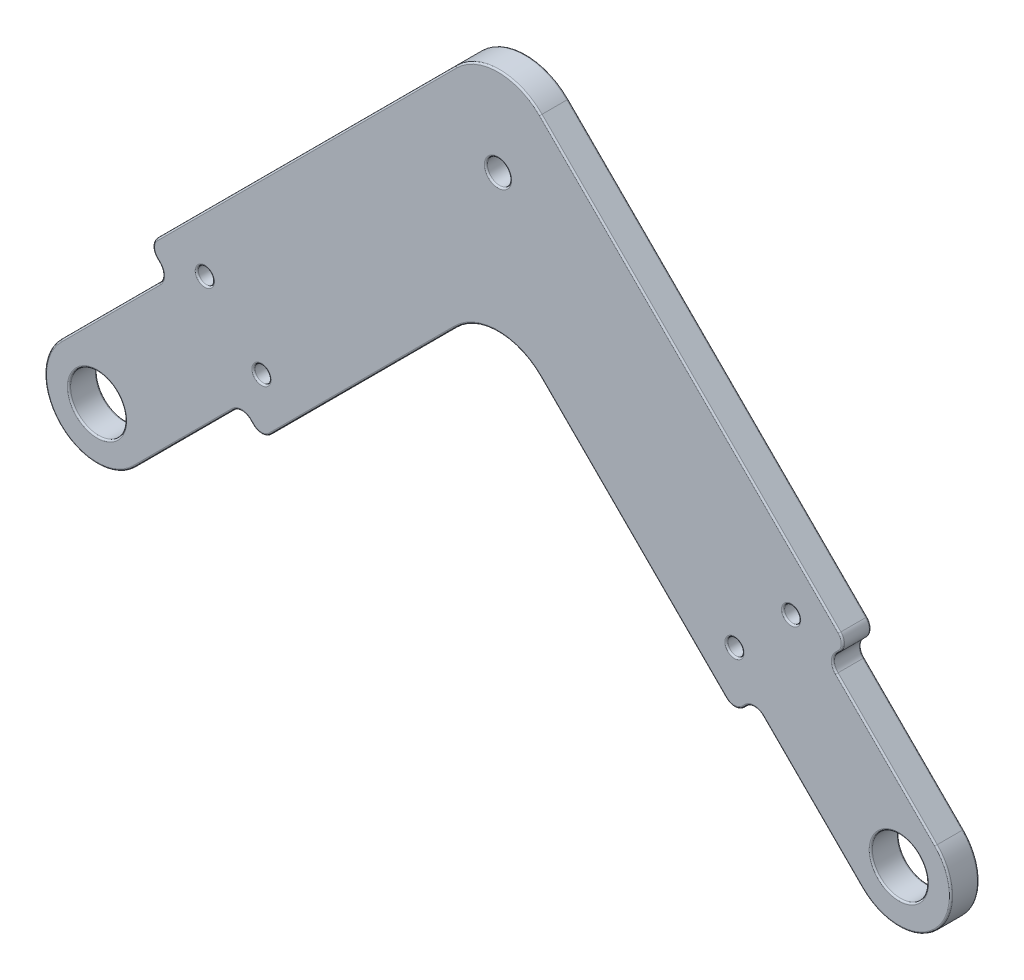
from build123d import *

# Parameters (mm, degrees)
SKETCH3_R           = 3.5
SKETCH3_R_2         = 1
SKETCH3_R_3         = 1.5
BOSS_EXTRUDE1_DEPTH = 3.5
FILLET1_R           = 7.5
FILLET2_R           = 1.5
FILLET3_R           = 0.2


with BuildPart() as part:
    # Sketch3 → Boss-Extrude1 (new body)
    with BuildSketch(Plane.XY):
        with BuildLine():
            Line((-79.493903346, 6.363961031), (-50, 35.857864376))
            Line((-50, 35.857864376), (-20.506096654, 6.363961031))
            Line((-20.506096654, 6.363961031), (-18.03122292, 8.838834765))
            Line((-18.03122292, 8.838834765), (-4.596194078, -4.596194078))
            ThreePointArc((-4.596194078, -4.596194078), (4.596194078, -4.596194078), (4.596194078, 4.596194078))
            Line((4.596194078, 4.596194078), (-8.838834765, 18.03122292))
            Line((-8.838834765, 18.03122292), (-6.363961031, 20.506096654))
            Line((-6.363961031, 20.506096654), (-50, 64.142135624))
            Line((-50, 64.142135624), (-93.636038969, 20.506096654))
            Line((-93.636038969, 20.506096654), (-91.161165235, 18.03122292))
            Line((-91.161165235, 18.03122292), (-104.596194078, 4.596194078))
            ThreePointArc((-104.596194078, 4.596194078), (-104.596194078, -4.596194078), (-95.403805922, -4.596194078))
            Line((-95.403805922, -4.596194078), (-81.96877708, 8.838834765))
            Line((-81.96877708, 8.838834765), (-79.493903346, 6.363961031))
        make_face()
        with Locations((-100, 0)):
            Circle(SKETCH3_R, mode=Mode.SUBTRACT)
        Circle(SKETCH3_R, mode=Mode.SUBTRACT)
        with Locations((-86.564971157, 20.506096654)):
            Circle(SKETCH3_R_2, mode=Mode.SUBTRACT)
        with Locations((-79.493903346, 13.435028843)):
            Circle(SKETCH3_R_2, mode=Mode.SUBTRACT)
        with Locations((-13.435028843, 20.506096654)):
            Circle(SKETCH3_R_2, mode=Mode.SUBTRACT)
        with Locations((-20.506096654, 13.435028843)):
            Circle(SKETCH3_R_2, mode=Mode.SUBTRACT)
        with Locations((-50, 50)):
            Circle(SKETCH3_R_3, mode=Mode.SUBTRACT)
    extrude(amount=BOSS_EXTRUDE1_DEPTH)

    # Fillet1
    fillet1_edges = [part.edges().sort_by_distance(p)[0] for p in [
        (-50, 64.142135624, 1.75),
        (-50, 35.857864376, 1.75),
    ]]
    fillet(fillet1_edges, radius=FILLET1_R)

    # Fillet2
    fillet2_edges = [part.edges().sort_by_distance(p)[0] for p in [
        (-81.96877708, 8.838834765, 1.75),
        (-91.161165235, 18.03122292, 1.75),
        (-93.636038969, 20.506096654, 1.75),
        (-6.363961031, 20.506096654, 1.75),
        (-8.838834765, 18.03122292, 1.75),
        (-18.03122292, 8.838834765, 1.75),
        (-20.506096654, 6.363961031, 1.75),
        (-79.493903346, 6.363961031, 1.75),
    ]]
    fillet(fillet2_edges, radius=FILLET2_R)

    # Fillet3
    fillet3_edges = [part.edges().sort_by_distance(p)[0] for p in [
        (-91.782485579, 18.03122292, 0),
        (-91.782485579, 18.03122292, 3.5),
        (-81.96877708, 8.217514421, 0),
        (-81.96877708, 8.217514421, 3.5),
        (-18.03122292, 8.217514421, 0),
        (-18.03122292, 8.217514421, 3.5),
        (-8.217514421, 18.03122292, 0),
        (-8.217514421, 18.03122292, 3.5),
        (-89.216621587, 1.590990258, 0),
        (-104.596194078, -4.596194078, 0),
        (-1.590990258, 10.783378413, 0),
        (4.596194078, -4.596194078, 0),
        (4.596194078, -4.596194078, 3.5),
        (-1.590990258, 10.783378413, 3.5),
        (-103.5, 0, 0),
        (-103.5, 0, 3.5),
        (-3.5, 0, 0),
        (-3.5, 0, 3.5),
        (-87.564971157, 20.506096654, 0),
        (-87.564971157, 20.506096654, 3.5),
        (-80.493903346, 13.435028843, 0),
        (-80.493903346, 13.435028843, 3.5),
        (-14.435028843, 20.506096654, 0),
        (-14.435028843, 20.506096654, 3.5),
        (-104.596194078, -4.596194078, 3.5),
        (-21.506096654, 13.435028843, 0),
        (-21.506096654, 13.435028843, 3.5),
        (-89.216621587, 1.590990258, 3.5),
        (-51.5, 50, 0),
        (-51.5, 50, 3.5),
        (-33.131727984, 18.98959236, 0),
        (-33.131727984, 18.98959236, 3.5),
        (-73.939339828, 40.202795796, 0),
        (-73.939339828, 40.202795796, 3.5),
        (-50, 61.035533906, 0),
        (-50, 61.035533906, 3.5),
        (-50, 32.751262658, 0),
        (-50, 32.751262658, 3.5),
        (-98.409009742, 10.783378413, 0),
        (-98.409009742, 10.783378413, 3.5),
        (-92.398602102, 19.268659787, 0),
        (-92.398602102, 19.268659787, 3.5),
        (-26.060660172, 40.202795796, 0),
        (-7.601397898, 19.268659787, 0),
        (-10.783378413, 1.590990258, 0),
        (-19.268659787, 7.601397898, 0),
        (-66.868272016, 18.98959236, 0),
        (-80.731340213, 7.601397898, 0),
        (-6.985281374, 20.506096654, 0),
        (-20.506096654, 6.985281374, 0),
        (-79.493903346, 6.985281374, 0),
        (-93.014718626, 20.506096654, 0),
        (-26.060660172, 40.202795796, 3.5),
        (-80.731340213, 7.601397898, 3.5),
        (-66.868272016, 18.98959236, 3.5),
        (-19.268659787, 7.601397898, 3.5),
        (-10.783378413, 1.590990258, 3.5),
        (-7.601397898, 19.268659787, 3.5),
        (-6.985281374, 20.506096654, 3.5),
        (-20.506096654, 6.985281374, 3.5),
        (-79.493903346, 6.985281374, 3.5),
        (-93.014718626, 20.506096654, 3.5),
    ]]
    fillet(fillet3_edges, radius=FILLET3_R)


solid = part.part
